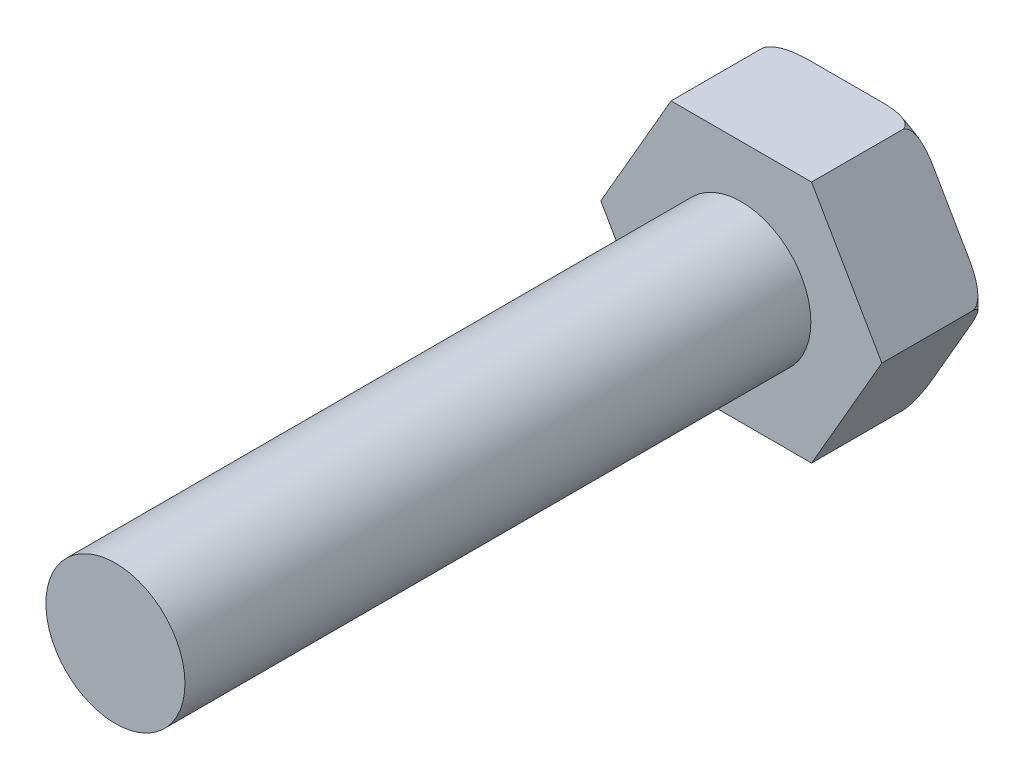
from build123d import *

# Parameters (mm, degrees)
BOSS_EXTRUDE1_DEPTH = 15
SKETCH2_R           = 10
BOSS_EXTRUDE2_DEPTH = 90


with BuildPart() as part:
    # Sketch1 → Boss-Extrude1 (new body)
    with BuildSketch(Plane.XY):
        Polygon((-20.207259422, 0), (-10.103629711, -17.5), (10.103629711, -17.5), (20.207259422, 0), (10.103629711, 17.5), (-10.103629711, 17.5), align=None)
    extrude(amount=BOSS_EXTRUDE1_DEPTH)

    # Sketch2 → Boss-Extrude2 (add)
    with BuildSketch(Plane.XY.offset(15)):
        Circle(SKETCH2_R)
    extrude(amount=BOSS_EXTRUDE2_DEPTH)

    # Sketch3 → Cut-Revolve2 (revolve, cut)
    with BuildSketch(Plane(origin=(0, 0, 0), x_dir=(1, 0, 0), z_dir=(0, 1, 0))):
        with BuildLine():
            Line((18.207259422, 0), (20.207259422, 0))
            Line((20.207259422, 0), (20.207259422, -2))
            ThreePointArc((20.207259422, -2), (19.621472984, -0.585786438), (18.207259422, 0))
        make_face()
    revolve(axis=Axis((0, 0, 105), (0, 0, -1)), mode=Mode.SUBTRACT)


solid = part.part
